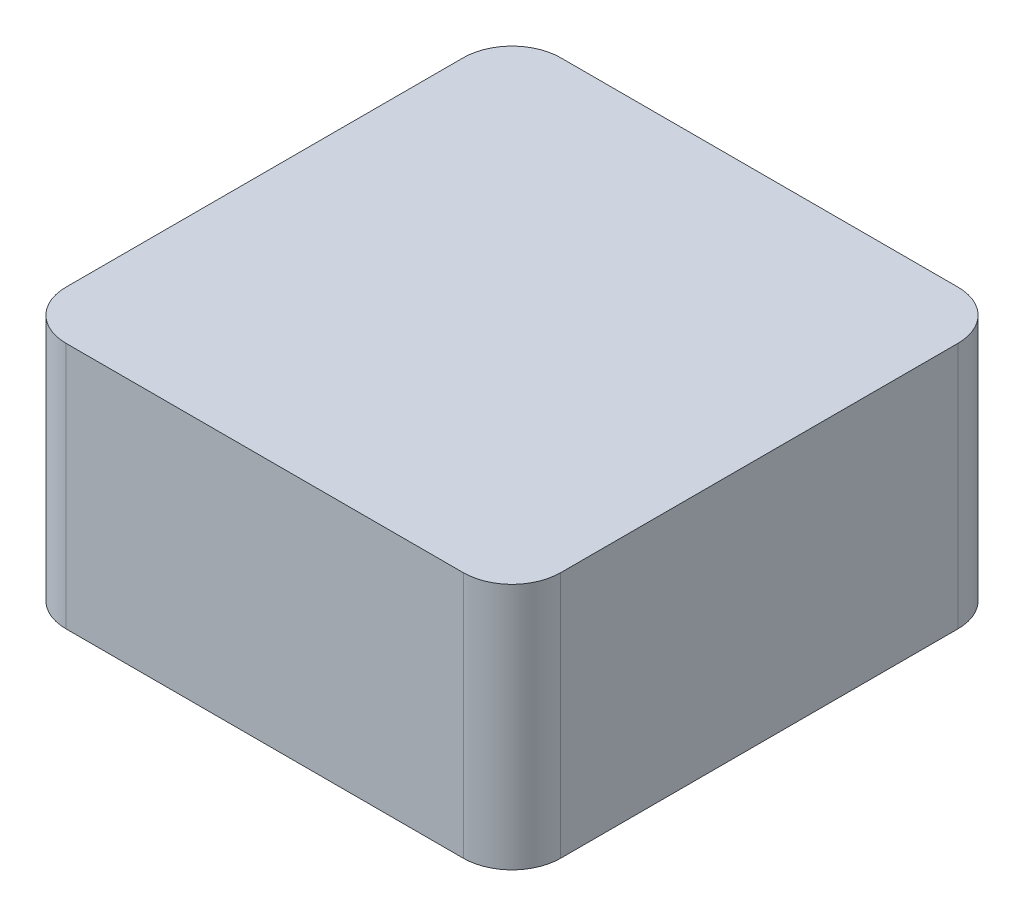
from build123d import *

# Parameters (mm, degrees)
SKETCH1_W           = 203.2
SKETCH1_H           = 101.6
BOSS_EXTRUDE2_DEPTH = 203.2
FILLET3_R           = 20
FILLET4_R           = 20
FILLET5_R           = 20
FILLET6_R           = 20
SKETCH2_W           = 152.4
SKETCH2_H           = 152.4
CUT_EXTRUDE1_DEPTH  = 88.9


with BuildPart() as part:
    # Sketch1 → Boss-Extrude2 (new body)
    with BuildSketch(Plane.XY):
        with Locations((101.6, 50.8)):
            Rectangle(SKETCH1_W, SKETCH1_H)
    extrude(amount=BOSS_EXTRUDE2_DEPTH)

    # Fillet3
    fillet3_edges = [part.edges().sort_by_distance(p)[0] for p in [
        (0, 50.8, 0),
    ]]
    fillet(fillet3_edges, radius=FILLET3_R)

    # Fillet4
    fillet4_edges = [part.edges().sort_by_distance(p)[0] for p in [
        (203.2, 50.8, 0),
    ]]
    fillet(fillet4_edges, radius=FILLET4_R)

    # Fillet5
    fillet5_edges = [part.edges().sort_by_distance(p)[0] for p in [
        (0, 50.8, 203.2),
    ]]
    fillet(fillet5_edges, radius=FILLET5_R)

    # Fillet6
    fillet6_edges = [part.edges().sort_by_distance(p)[0] for p in [
        (203.2, 50.8, 203.2),
    ]]
    fillet(fillet6_edges, radius=FILLET6_R)

    # Sketch2 → Cut-Extrude1 (cut)
    with BuildSketch(Plane.XZ):
        with Locations((100, 100)):
            Rectangle(SKETCH2_W, SKETCH2_H)
    extrude(amount=-CUT_EXTRUDE1_DEPTH, mode=Mode.SUBTRACT)


solid = part.part
